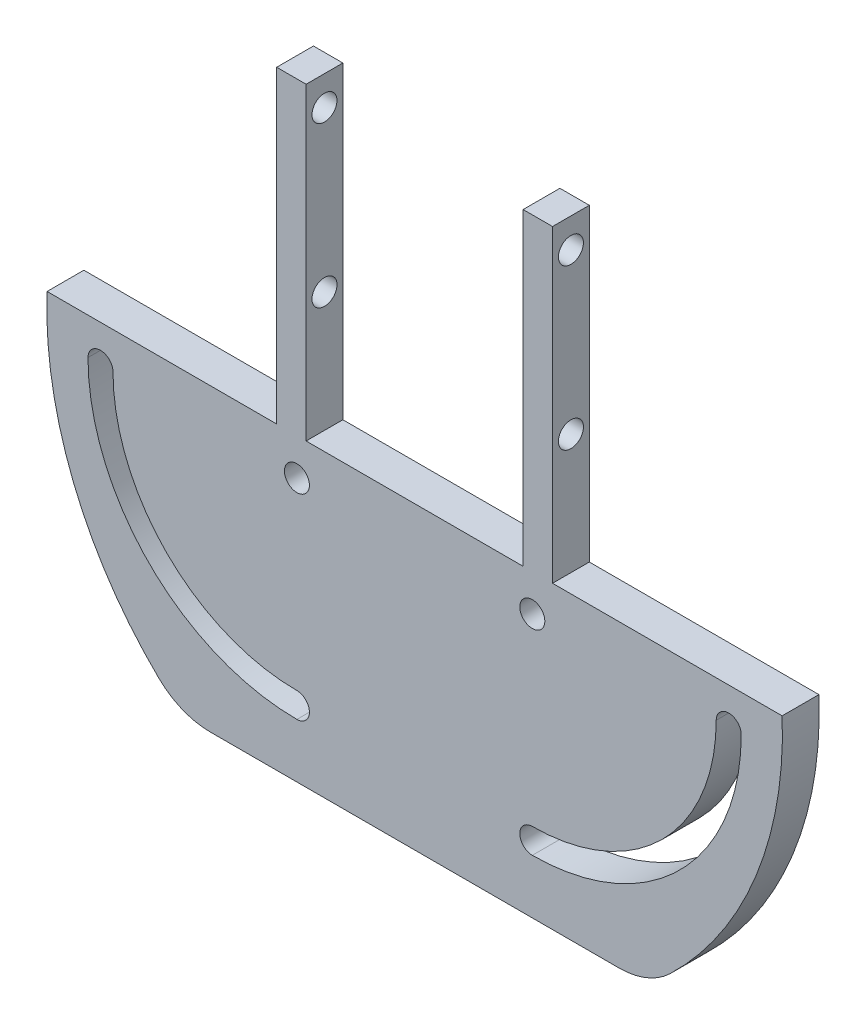
from build123d import *

# Parameters (mm, degrees)
SKETCH1_R           = 1.7
BOSS_EXTRUDE1_DEPTH = 5
SKETCH2_W           = 4
SKETCH2_H           = 5
BOSS_EXTRUDE2_DEPTH = 42
SKETCH3_R           = 1.7
CUT_EXTRUDE1_DEPTH  = 69.75
FILLET1_R           = 10
FILLET2_R           = 10


with BuildPart() as part:
    # Sketch1 → Boss-Extrude1 (new body)
    with BuildSketch(Plane.XY):
        with BuildLine():
            Line((-49.959983987, 2), (49.959983987, 2))
            ThreePointArc((49.959983987, 2), (45.578077054, -20.558183092), (31.568754239, -38.773879814))
            Line((31.568754239, -38.773879814), (-31.568754239, -38.773879814))
            ThreePointArc((-31.568754239, -38.773879814), (-45.578077054, -20.558183092), (-49.959983987, 2))
        make_face()
        with Locations((-16, -3)):
            Circle(SKETCH1_R, mode=Mode.SUBTRACT)
        with Locations((16, -3)):
            Circle(SKETCH1_R, mode=Mode.SUBTRACT)
        with BuildLine():
            ThreePointArc((-44.4, -3), (-36.081832586, -23.081832586), (-16, -31.4))
            ThreePointArc((-16, -31.4), (-14.3, -29.7), (-16, -28))
            ThreePointArc((-16, -28), (-33.67766953, -20.67766953), (-41, -3))
            ThreePointArc((-41, -3), (-42.7, -1.3), (-44.4, -3))
        make_face(mode=Mode.SUBTRACT)
        with BuildLine():
            ThreePointArc((16, -31.4), (36.081832586, -23.081832586), (44.4, -3))
            ThreePointArc((44.4, -3), (42.7, -1.3), (41, -3))
            ThreePointArc((41, -3), (33.67766953, -20.67766953), (16, -28))
            ThreePointArc((16, -28), (14.3, -29.7), (16, -31.4))
        make_face(mode=Mode.SUBTRACT)
    extrude(amount=-BOSS_EXTRUDE1_DEPTH)

    # Sketch2 → Boss-Extrude2 (add)
    with BuildSketch(Plane(origin=(0, 2, 0), x_dir=(1, 0, 0), z_dir=(0, 1, 0))):
        with Locations((16.75, 2.5)):
            Rectangle(SKETCH2_W, SKETCH2_H)
        with Locations((-16.75, 2.5)):
            Rectangle(SKETCH2_W, SKETCH2_H)
    extrude(amount=BOSS_EXTRUDE2_DEPTH)

    # Sketch3 → Cut-Extrude1 (cut, through all)
    with BuildSketch(Plane(origin=(18.75, 0, 0), x_dir=(0, 0, -1), z_dir=(1, 0, 0))):
        with Locations((2.5, 40)):
            Circle(SKETCH3_R)
        with Locations((2.5, 18.3)):
            Circle(SKETCH3_R)
    extrude(amount=-CUT_EXTRUDE1_DEPTH, mode=Mode.SUBTRACT)

    # Fillet1
    fillet1_edges = [part.edges().sort_by_distance(p)[0] for p in [
        (31.568754239, -38.773879814, -2.5),
    ]]
    fillet(fillet1_edges, radius=FILLET1_R)

    # Fillet2
    fillet2_edges = [part.edges().sort_by_distance(p)[0] for p in [
        (-31.568754239, -38.773879814, -2.5),
    ]]
    fillet(fillet2_edges, radius=FILLET2_R)


solid = part.part
